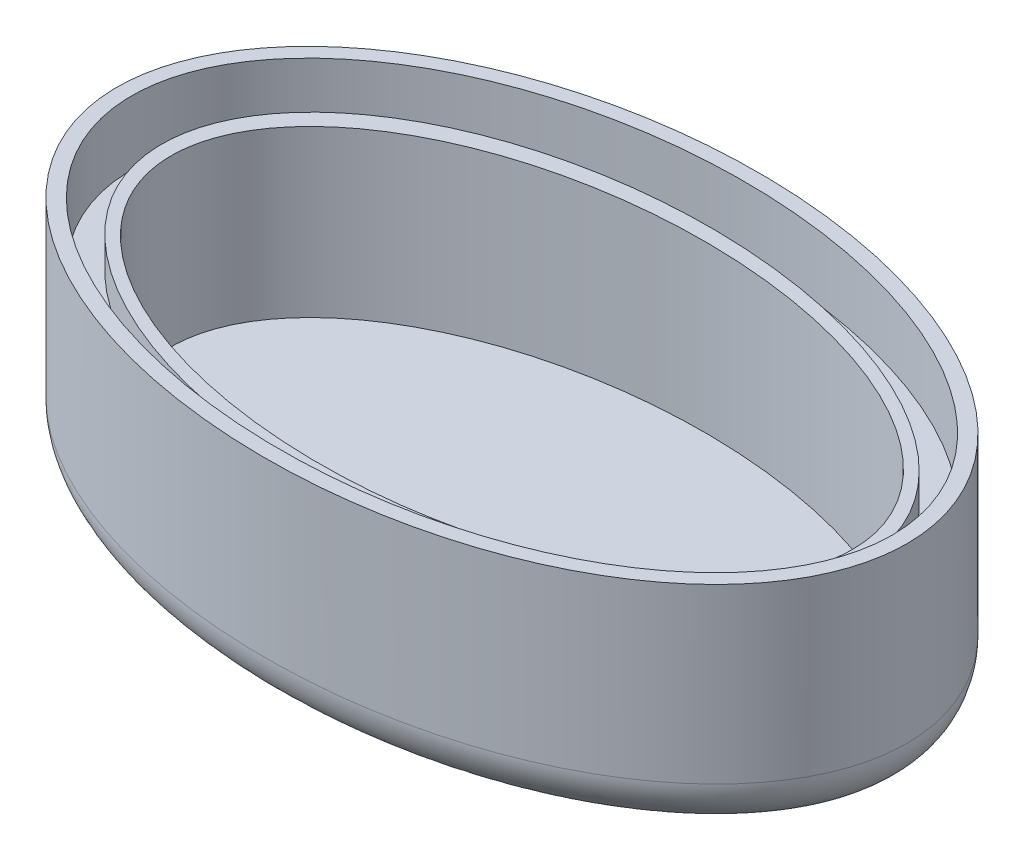
from build123d import *

# Parameters (mm, degrees)
SKETCH2_RX          = 80
SKETCH2_RY          = 50
BOSS_EXTRUDE1_DEPTH = 45
FILLET2_R           = 10
SKETCH3_RX          = 69
SKETCH3_RY          = 39
CUT_EXTRUDE1_DEPTH  = 40
SKETCH4_RX          = 77
SKETCH4_RY          = 47
CUT_EXTRUDE2_DEPTH  = 13
SKETCH5_RX          = 72
SKETCH5_RY          = 42
SKETCH5_RX_2        = 69
SKETCH5_RY_2        = 39
BOSS_EXTRUDE2_DEPTH = 6.5


with BuildPart() as part:
    # Sketch2 → Boss-Extrude1 (new body)
    with BuildSketch(Plane(origin=(0, 0, 0), x_dir=(1, 0, 0), z_dir=(0, 1, 0))):
        with Locations((0, 0)):
            Ellipse(SKETCH2_RX, SKETCH2_RY)
    extrude(amount=BOSS_EXTRUDE1_DEPTH)

    # Fillet2
    fillet2_edges = [part.edges().sort_by_distance(p)[0] for p in [
        (-79.999879829, 0, 0.086664306),
    ]]
    fillet(fillet2_edges, radius=FILLET2_R)

    # Sketch3 → Cut-Extrude1 (cut)
    with BuildSketch(Plane(origin=(0, 45, 0), x_dir=(1, 0, 0), z_dir=(0, 1, 0))):
        with Locations((0, 0)):
            Ellipse(SKETCH3_RX, SKETCH3_RY)
    extrude(amount=-CUT_EXTRUDE1_DEPTH, mode=Mode.SUBTRACT)

    # Sketch4 → Cut-Extrude2 (cut)
    with BuildSketch(Plane(origin=(0, 45, 0), x_dir=(1, 0, 0), z_dir=(0, 1, 0))):
        with Locations((0, 0)):
            Ellipse(SKETCH4_RX, SKETCH4_RY)
    extrude(amount=-CUT_EXTRUDE2_DEPTH, mode=Mode.SUBTRACT)

    # Sketch5 → Boss-Extrude2 (add)
    with BuildSketch(Plane(origin=(0, 32, 0), x_dir=(1, 0, 0), z_dir=(0, 1, 0))):
        with Locations(Location((0, 0), (0, 0, -1.279425375))):
            Ellipse(SKETCH5_RX, SKETCH5_RY)
        with Locations((0, 0)):
            Ellipse(SKETCH5_RX_2, SKETCH5_RY_2, mode=Mode.SUBTRACT)
    extrude(amount=BOSS_EXTRUDE2_DEPTH)


solid = part.part
